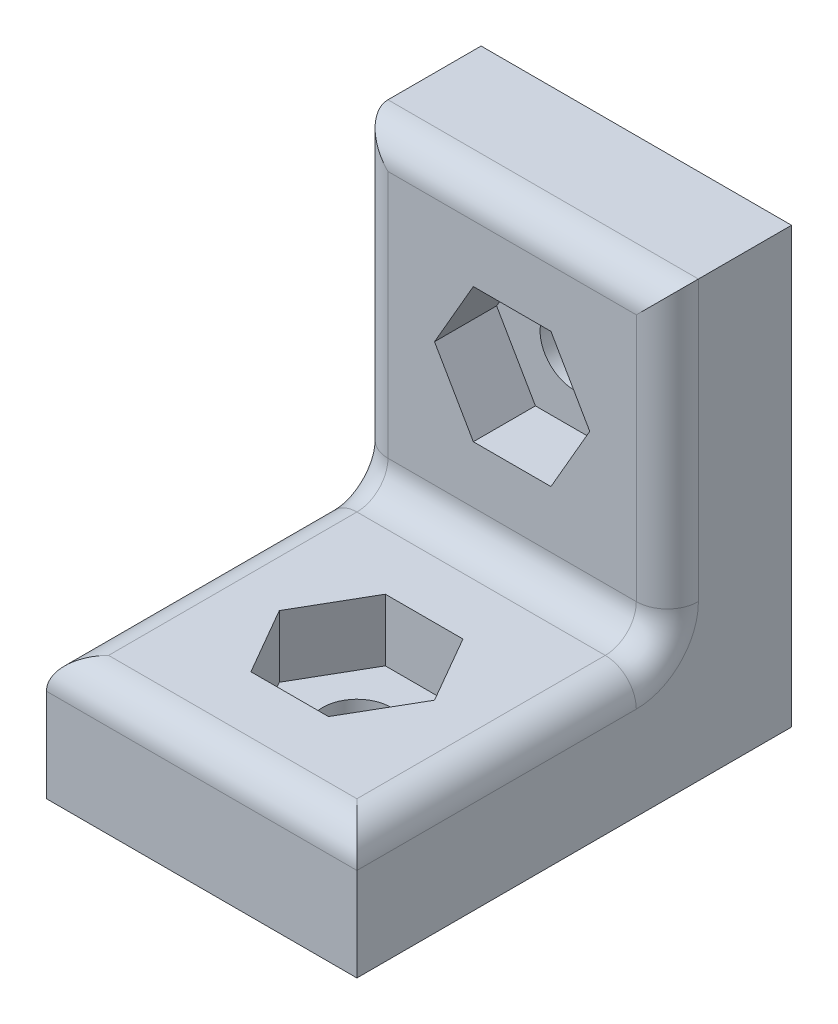
from build123d import *

# Parameters (mm, degrees)
ESQUISSE1_W             = 10
ESQUISSE1_H             = 14
BOSS_EXTRU_1_DEPTH      = 4
ESQUISSE2_W             = 10
ESQUISSE2_H             = 4
BOSS_EXTRU_2_DEPTH      = 10
ESQUISSE3_R             = 1.1
ENL_V_MAT_EXTRU_1_DEPTH = 5
CONG_1_R                = 1
ESQUISSE4_R             = 1.1
ENL_V_MAT_EXTRU_2_DEPTH = 5
ENL_V_MAT_EXTRU_3_DEPTH = 2
ENL_V_MAT_EXTRU_4_DEPTH = 2


with BuildPart() as part:
    # Esquisse1 → Boss.-Extru.1 (new body)
    with BuildSketch(Plane.XY):
        with Locations((0, 7)):
            Rectangle(ESQUISSE1_W, ESQUISSE1_H)
    extrude(amount=BOSS_EXTRU_1_DEPTH)

    # Esquisse2 → Boss.-Extru.2 (add)
    with BuildSketch(Plane.XY.offset(4)):
        with Locations((0, 2)):
            Rectangle(ESQUISSE2_W, ESQUISSE2_H)
    extrude(amount=BOSS_EXTRU_2_DEPTH)

    # Esquisse3 → Enlèv. mat.-Extru.1 (cut, through all)
    with BuildSketch(Plane.XY.offset(4)):
        with Locations((0, 9)):
            Circle(ESQUISSE3_R)
    extrude(amount=-ENL_V_MAT_EXTRU_1_DEPTH, mode=Mode.SUBTRACT)

    # Congé1
    cong_1_edges = [part.edges().sort_by_distance(p)[0] for p in [
        (5, 9, 4),
        (-5, 4, 9),
        (0, 4, 4),
        (5, 4, 9),
        (0, 14, 4),
        (0, 4, 14),
        (-5, 9, 4),
    ]]
    fillet(cong_1_edges, radius=CONG_1_R)

    # Esquisse4 → Enlèv. mat.-Extru.2 (cut, through all)
    with BuildSketch(Plane(origin=(0, 4, 0), x_dir=(1, 0, 0), z_dir=(0, 1, 0))):
        with Locations(Location((0, -9, 0), (0, 0, 270))):  # turned: the seam where the file's is
            Circle(ESQUISSE4_R)
    extrude(amount=-ENL_V_MAT_EXTRU_2_DEPTH, mode=Mode.SUBTRACT)

    # Esquisse5 → Enlèv. mat.-Extru.3 (cut)
    with BuildSketch(Plane.XY.offset(4)):
        Polygon((1.25, 6.834936491), (2.5, 9), (1.25, 11.165063509), (-1.25, 11.165063509), (-2.5, 9), (-1.25, 6.834936491), align=None)
    extrude(amount=-ENL_V_MAT_EXTRU_3_DEPTH, mode=Mode.SUBTRACT)

    # Esquisse6 → Enlèv. mat.-Extru.4 (cut)
    with BuildSketch(Plane(origin=(0, 4, 0), x_dir=(1, 0, 0), z_dir=(0, 1, 0))):
        Polygon((2.5, -9), (1.25, -6.834936491), (-1.25, -6.834936491), (-2.5, -9), (-1.25, -11.165063509), (1.25, -11.165063509), align=None)
    extrude(amount=-ENL_V_MAT_EXTRU_4_DEPTH, mode=Mode.SUBTRACT)


solid = part.part
